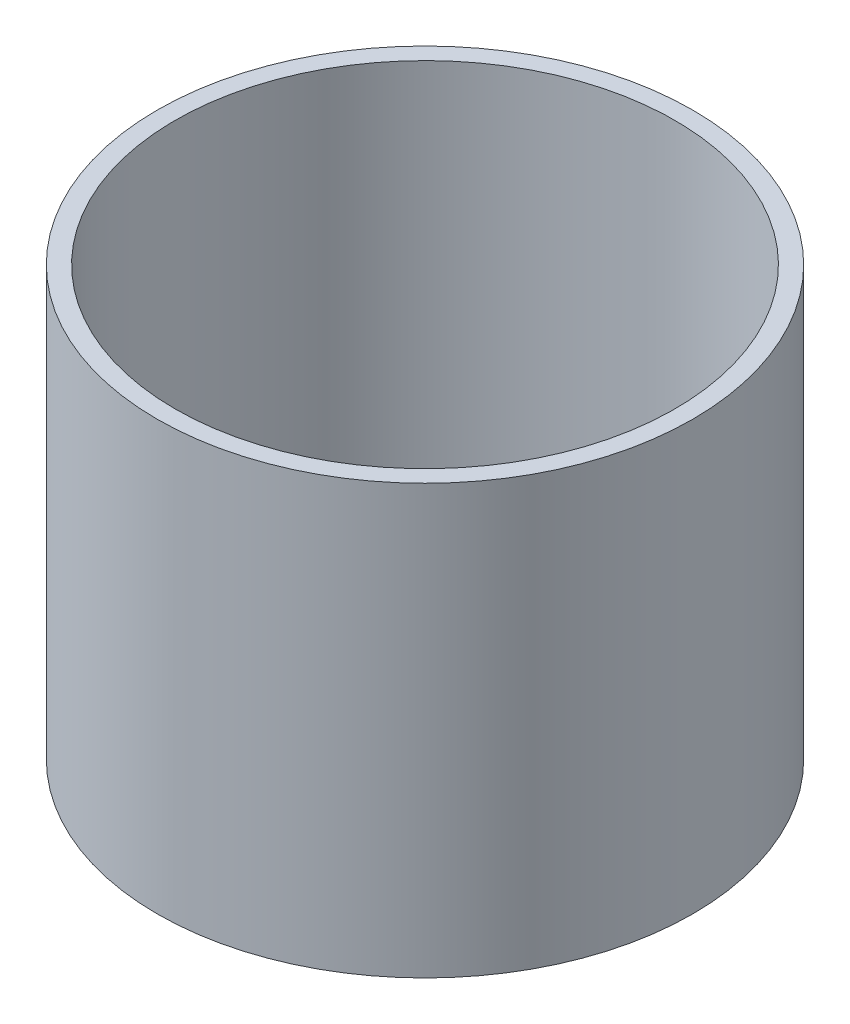
from build123d import *

# Parameters (mm, degrees)
SKETCH1_R           = 47.625
SKETCH1_R_2         = 44.45
BOSS_EXTRUDE1_DEPTH = 76.2


with BuildPart() as part:
    # Sketch1 → Boss-Extrude1 (new body)
    with BuildSketch(Plane(origin=(0, 0, 0), x_dir=(1, 0, 0), z_dir=(0, 1, 0))):
        Circle(SKETCH1_R)
        Circle(SKETCH1_R_2, mode=Mode.SUBTRACT)
    extrude(amount=BOSS_EXTRUDE1_DEPTH)


solid = part.part
